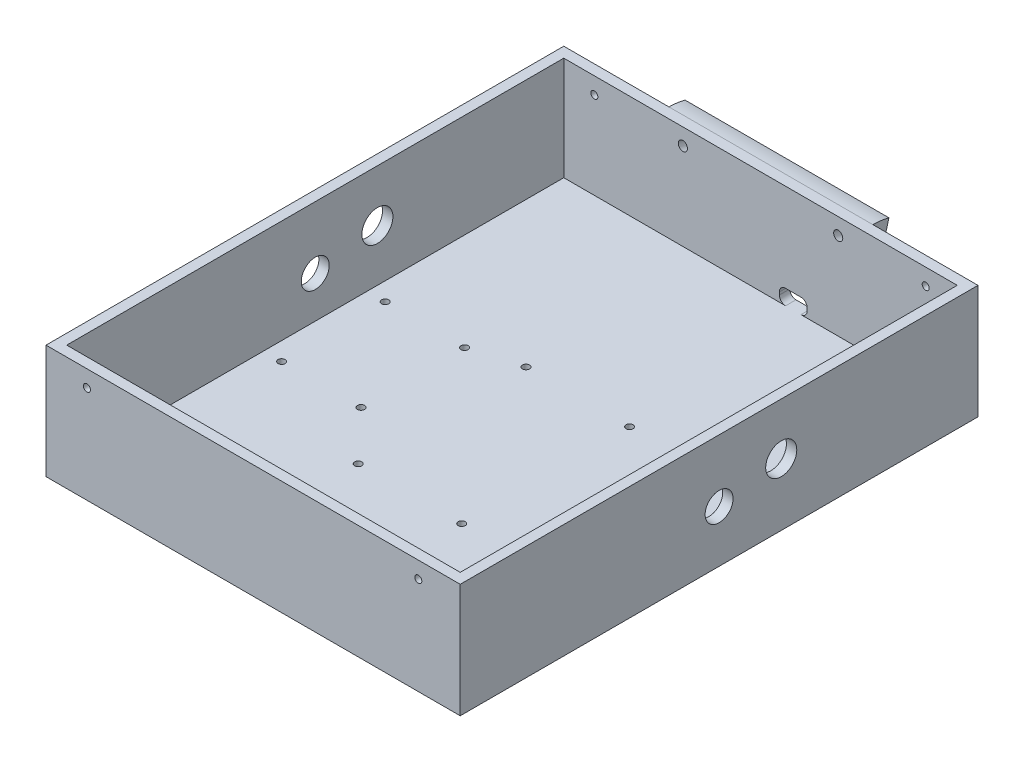
from build123d import *

# Parameters (mm, degrees)
SKETCH1_W               = 190
SKETCH1_H               = 50
BOSS_EXTRUDE1_DEPTH     = 120
SHELL1_T                = 5
SKETCH3_R               = 6.75
CUT_EXTRUDE2_DEPTH      = 242.091269025
CUT_EXTRUDE2_DEPTH_BACK = 242.091269025
M3_CLEARANCE_HOLE1_D    = 3.4
SKETCH8_R               = 7.5
CUT_EXTRUDE4_DEPTH      = 168.705098312
CUT_EXTRUDE4_DEPTH_BACK = 168.705098312
SKETCH10_W              = 13.4
SKETCH10_H              = 7.3
CUT_EXTRUDE6_DEPTH      = 5
FILLET1_R               = 3
SKETCH11_W              = 98.43460289
SKETCH11_H              = 30
REVOLVE1_ANGLE          = 15
CUT_EXTRUDE7_REACH      = 271.031
SKETCH12_R              = 2.2
M3_CLEARANCE_HOLE3_D    = 3.4


with BuildPart() as part:
    # Sketch1 → Boss-Extrude1 (new, symmetric)
    with BuildSketch(Plane.XY):
        with Locations((0, 25)):
            Rectangle(SKETCH1_W, SKETCH1_H)
    extrude(amount=BOSS_EXTRUDE1_DEPTH, both=True)

    # Shell1
    shell1_openings = [part.faces().sort_by_distance(p)[0] for p in [
        (0, 50, 0),
    ]]
    offset(amount=SHELL1_T, openings=shell1_openings, kind=Kind.INTERSECTION)

    # Sketch3 → Cut-Extrude2 (cut, two sides)
    with BuildSketch(Plane(origin=(100, 0, 0), x_dir=(0, 0, -1), z_dir=(1, 0, 0))) as cut_extrude2_sk:
        with Locations(Location((0, 20, 0), (0, 0, 270))):
            Circle(SKETCH3_R)
    extrude(amount=CUT_EXTRUDE2_DEPTH, mode=Mode.SUBTRACT)
    extrude(cut_extrude2_sk.sketch, amount=-CUT_EXTRUDE2_DEPTH_BACK, mode=Mode.SUBTRACT)

    # M3 Clearance Hole1 (through all)
    with Locations(Plane.XY.offset(125)):
        with Locations((-80.25, 42), (79.75, 42)):
            Hole(M3_CLEARANCE_HOLE1_D / 2)

    # Sketch8 → Cut-Extrude4 (cut, two sides)
    with BuildSketch(Plane(origin=(0, 0, 0), x_dir=(0, 0, -1), z_dir=(1, 0, 0))) as cut_extrude4_sk:
        with Locations((30, 25)):
            Circle(SKETCH8_R)
    extrude(amount=CUT_EXTRUDE4_DEPTH, mode=Mode.SUBTRACT)
    extrude(cut_extrude4_sk.sketch, amount=-CUT_EXTRUDE4_DEPTH_BACK, mode=Mode.SUBTRACT)

    # Sketch10 → Cut-Extrude6 (cut)
    with BuildSketch(Plane(origin=(0, 0, -125), x_dir=(-1, 0, 0), z_dir=(0, 0, -1))):
        with Locations((-15.8, 3.65)):
            Rectangle(SKETCH10_W, SKETCH10_H)
    extrude(amount=-CUT_EXTRUDE6_DEPTH, mode=Mode.SUBTRACT)

    # Fillet1
    fillet1_edges = [part.edges().sort_by_distance(p)[0] for p in [
        (22.5, 0, -122.5),
        (22.5, 7.3, -122.5),
        (9.1, 7.3, -122.5),
        (9.1, 0, -122.5),
    ]]
    fillet(fillet1_edges, radius=FILLET1_R)

    # Sketch11 → Revolve1 (revolve)
    with BuildSketch(Plane(origin=(0, 0, -125), x_dir=(-1, 0, 0), z_dir=(0, 0, -1))):
        with Locations((0, 35)):
            Rectangle(SKETCH11_W, SKETCH11_H)
    revolve(axis=Axis((49.217301445, 20, -125), (-1, 0, 0)), revolution_arc=REVOLVE1_ANGLE)

    # Cut-Extrude7: up to this plane
    cut_extrude7_end = Plane(origin=(0, 0, -120), z_dir=(0, 0, -1))
    # Sketch12 → Cut-Extrude7 (cut, up to the surface)
    with BuildSketch(Plane(origin=(0, -29.910254038, -111.626587737), x_dir=(-1, 0, 0), z_dir=(0, -0.25881904510252135, -0.9659258262890682)), mode=Mode.PRIVATE) as cut_extrude7_sk1:
        with Locations(Location((-37.5, 71.670897164, 0), (0, 0, 90))):
            Circle(SKETCH12_R)
    cut_extrude7_tool1 = split(extrude(cut_extrude7_sk1.sketch, amount=-CUT_EXTRUDE7_REACH, mode=Mode.PRIVATE), bisect_by=cut_extrude7_end, keep=Keep.BOTH, mode=Mode.PRIVATE)
    cut_extrude7 = cut_extrude7_tool1.solids().sort_by_distance((37.5, 39.318517, -130.176381))[0]
    add(cut_extrude7, mode=Mode.SUBTRACT)

    # Mirror2: Cut-Extrude7 across plane
    add(cut_extrude7.mirror(Plane(origin=(0, 0, 0), x_dir=(0, 0, 1), z_dir=(1, 0, 0))), mode=Mode.SUBTRACT)

    # M3 Clearance Hole3 (through all)
    with Locations(Plane(origin=(0, 5, 0), x_dir=(1, 0, 0), z_dir=(0, 1, 0))):
        with Locations((-47.903181707, 25), (-86.25, 25), (-47.903181707, -25), (-86.25, -25), (25, -49.28), (47.903181707, -25), (86.25, -25), (86.25, 25), (47.903181707, 25), (25, 31.75), (-25, 31.75), (-25, -49.28)):
            Hole(M3_CLEARANCE_HOLE3_D / 2)


solid = part.part
